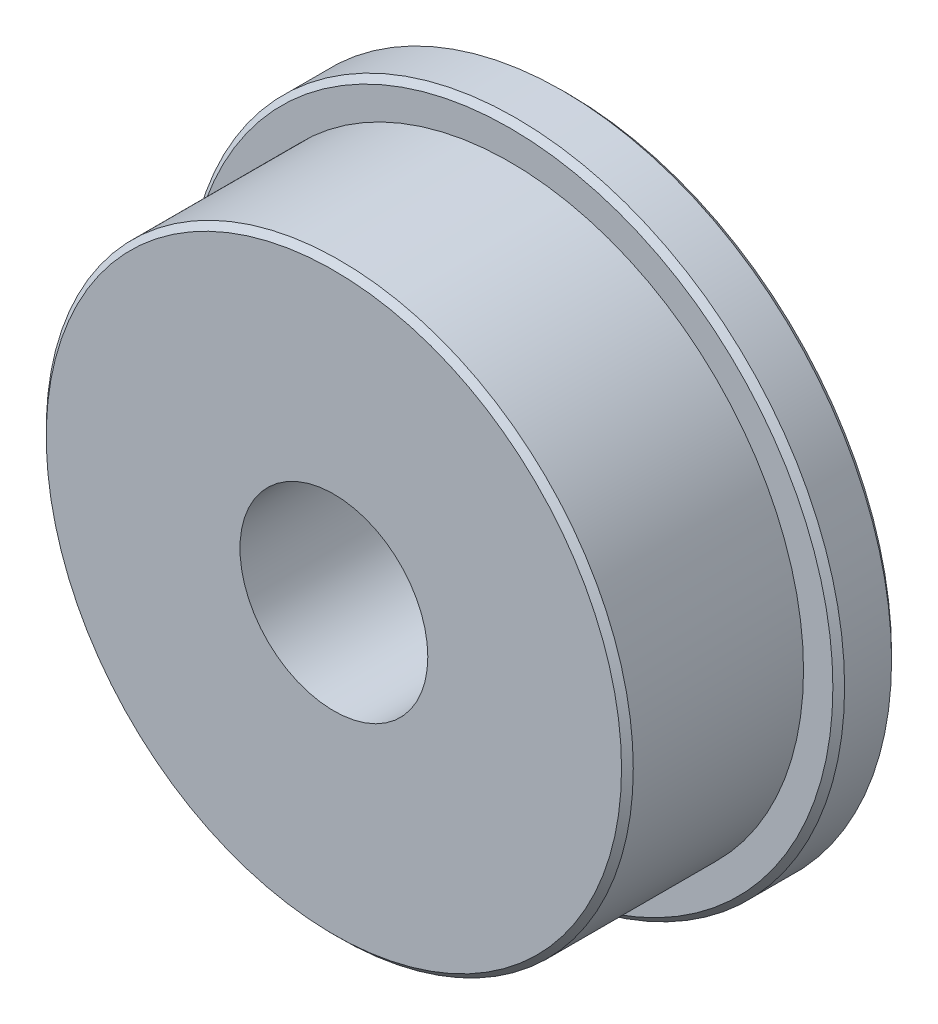
from build123d import *


with BuildPart() as part:
    # Croquis1 → Revolución1 (revolve)
    with BuildSketch(Plane(origin=(0, 0, 0), x_dir=(1, 0, 0), z_dir=(0, 1, 0))):
        Polygon((5, -3.9), (5, -1), (5.5, -1), (5.6, -0.9), (5.6, -0.1), (5.5, 0), (1.6, 0), (1.6, -4), (4.9, -4), align=None)
    revolve(axis=Axis((0, 0, 0), (0, 0, 1)))


solid = part.part
